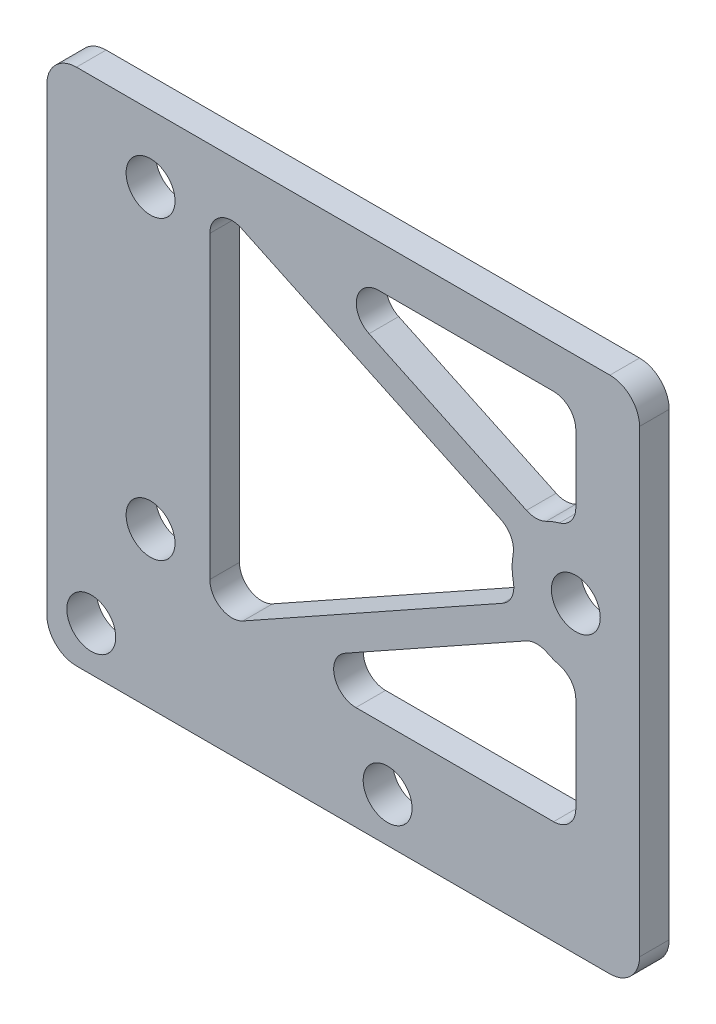
from build123d import *

# Parameters (mm, degrees)
SKETCH_1_W          = 40
SKETCH_1_H          = 35
EXTRUDE_1_DEPTH     = 2
SKETCH_2_R          = 1.65
CUT_EXTRUDE_1_DEPTH = 2
FILLET_1_R          = 2
CUT_EXTRUDE_2_DEPTH = 10
FILLET_2_R          = 1.5


with BuildPart() as part:
    # 草图1 → 凸台-拉伸1 (new body)
    with BuildSketch(Plane.XY):
        Rectangle(SKETCH_1_W, SKETCH_1_H)
    extrude(amount=EXTRUDE_1_DEPTH)

    # 草图2 → 切除-拉伸1 (cut)
    with BuildSketch(Plane.XY.offset(2)):
        with Locations((-17, -14.5)):
            Circle(SKETCH_2_R)
        with Locations((3, -14.5)):
            Circle(SKETCH_2_R)
        with Locations((-13, -7)):
            Circle(SKETCH_2_R)
        with Locations((-13, 13)):
            Circle(SKETCH_2_R)
        with Locations((15.7, 3)):
            Circle(SKETCH_2_R)
    extrude(amount=-CUT_EXTRUDE_1_DEPTH, mode=Mode.SUBTRACT)

    # 圆角1
    fillet_1_edges = [part.edges().sort_by_distance(p)[0] for p in [
        (20, -17.5, 1),
        (-20, -17.5, 1),
        (-20, 17.5, 1),
        (20, 17.5, 1),
    ]]
    fillet(fillet_1_edges, radius=FILLET_1_R)

    # 草图3 → 切除-拉伸2 (cut)
    with BuildSketch(Plane.XY.offset(2)):
        with BuildLine():
            Line((-9, 14.65), (-9, -10.5))
            Line((-9, -10.5), (11.823480969, 1.139193668))
            ThreePointArc((11.823480969, 1.139193668), (11.400024975, 2.985344434), (11.81088684, 4.834338798))
            Line((11.81088684, 4.834338798), (-9, 14.65))
        make_face()
        with BuildLine():
            Line((-4.900820963, -10.5), (15.7, -10.5))
            Line((15.7, -10.5), (15.7, -1.3))
            ThreePointArc((15.7, -1.3), (14.334491183, -1.077423901), (13.110344983, -0.432737522))
            Line((13.110344983, -0.432737522), (-4.900820963, -10.5))
        make_face()
        with BuildLine():
            Line((-4.31166216, 14.65), (15.7, 14.65))
            Line((15.7, 14.65), (15.7, 7.3))
            ThreePointArc((15.7, 7.3), (14.334491183, 7.077423901), (13.110344983, 6.432737522))
            Line((13.110344983, 6.432737522), (-4.31166216, 14.65))
        make_face()
    extrude(amount=-CUT_EXTRUDE_2_DEPTH, mode=Mode.SUBTRACT)

    # 圆角2
    fillet_2_edges = [part.edges().sort_by_distance(p)[0] for p in [
        (-4.900820963, -10.5, 1),
        (13.110344983, -0.432737522, 1),
        (15.7, -1.3, 1),
        (15.7, -10.5, 1),
        (13.110344983, 6.432737522, 1),
        (-4.31166216, 14.65, 1),
        (15.7, 14.65, 1),
        (15.7, 7.3, 1),
        (-9, 14.65, 1),
        (11.81088684, 4.834338798, 1),
        (11.823480969, 1.139193668, 1),
        (-9, -10.5, 1),
    ]]
    fillet(fillet_2_edges, radius=FILLET_2_R)


solid = part.part
